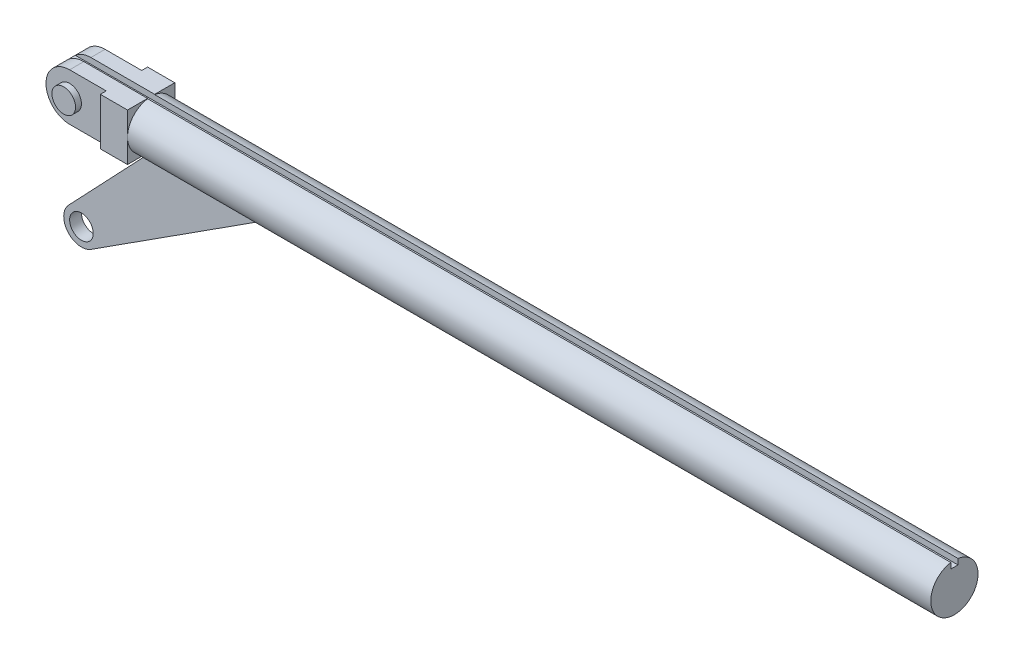
from build123d import *

# Parameters (mm, degrees)
SKETCH_1_R               = 2
EXTRUDE_1_DEPTH          = 68
EXTRUDE_2_DEPTH          = 2
SKETCH_3_W               = 5.1
SKETCH_3_H               = 0.5
CUT_EXTRUDE_1_DEPTH      = 3
CUT_EXTRUDE_1_DEPTH_BACK = 3
SKETCH_4_R               = 1
EXTRUDE_3_DEPTH          = 2
SKETCH_5_W               = 75.4
SKETCH_5_H               = 0.6
CUT_EXTRUDE_2_DEPTH      = 0.5
SKETCH_6_R               = 1
EXTRUDE_4_DEPTH          = 0.5


with BuildPart() as part:
    # 草图1 → 凸台-拉伸1 (new body)
    with BuildSketch(Plane(origin=(0, 0, 0), x_dir=(0, 0, -1), z_dir=(1, 0, 0))):
        Circle(SKETCH_1_R)
    extrude(amount=-EXTRUDE_1_DEPTH)

    # 草图2 → 凸台-拉伸2 (add, symmetric)
    with BuildSketch(Plane.XY):
        with BuildLine():
            Line((-68, 2), (-73.4, 2))
            ThreePointArc((-73.4, 2), (-75.4, 0), (-73.4, -2))
            Line((-73.4, -2), (-68, -2))
            Line((-68, -2), (-68, 2))
        make_face()
    extrude(amount=EXTRUDE_2_DEPTH, both=True)

    # 草图3 → 切除-拉伸1 (cut, two sides)
    with BuildSketch(Plane(origin=(0, 0, 0), x_dir=(1, 0, 0), z_dir=(0, 1, 0))) as cut_extrude_1_sk:
        with Locations((-72.85, 1.75)):
            Rectangle(SKETCH_3_W, SKETCH_3_H)
        with Locations((-72.85, -1.75)):
            Rectangle(SKETCH_3_W, SKETCH_3_H)
    extrude(amount=CUT_EXTRUDE_1_DEPTH, mode=Mode.SUBTRACT)
    extrude(cut_extrude_1_sk.sketch, amount=-CUT_EXTRUDE_1_DEPTH_BACK, mode=Mode.SUBTRACT)

    # 草图4 → 凸台-拉伸3 (add, symmetric)
    with BuildSketch(Plane.XY):
        with Locations((-73.4, 0)):
            Circle(SKETCH_4_R)
    extrude(amount=EXTRUDE_3_DEPTH, both=True)

    # 草图5 → 切除-拉伸2 (cut)
    with BuildSketch(Plane(origin=(0, 2, 0), x_dir=(1, 0, 0), z_dir=(0, 1, 0))):
        with Locations((-37.7, 0)):
            Rectangle(SKETCH_5_W, SKETCH_5_H)
    extrude(amount=-CUT_EXTRUDE_2_DEPTH, mode=Mode.SUBTRACT)

    # 草图6 → 凸台-拉伸4 (add, symmetric)
    with BuildSketch(Plane.XY):
        with BuildLine():
            Line((-67.4, -1.5), (-57.4, -1.5))
            Line((-57.4, -1.5), (-72.589010682, -11.261862245))
            ThreePointArc((-72.589010682, -11.261862245), (-74.555588863, -10.956354736), (-74.487937961, -8.96733791))
            Line((-74.487937961, -8.96733791), (-67.4, -1.5))
        make_face()
        with Locations((-73.4, -10)):
            Circle(SKETCH_6_R, mode=Mode.SUBTRACT)
    extrude(amount=EXTRUDE_4_DEPTH, both=True)


solid = part.part
